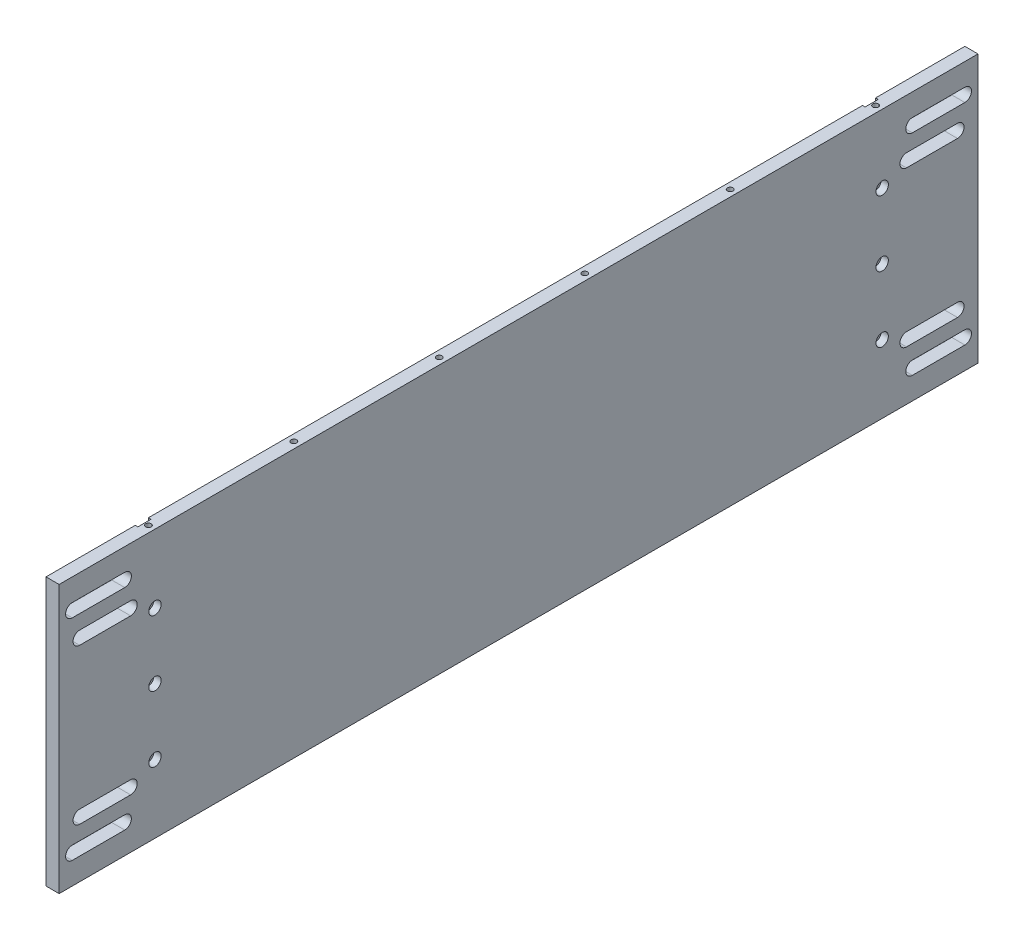
from build123d import *

# Parameters (mm, degrees)
SKETCH1_W                                      = 444.5
SKETCH1_H                                      = 129.54
BOSS_EXTRUDE1_DEPTH                            = 6.35
CBORE_FOR_6_SOCKET_HEAD_CAP_SCREW1_D           = 3.6576
CBORE_FOR_6_SOCKET_HEAD_CAP_SCREW1_CBORE_D     = 5.999999938
CBORE_FOR_6_SOCKET_HEAD_CAP_SCREW1_CBORE_DEPTH = 3.5052
CUT_EXTRUDE1_DEPTH                             = 7.35
TAP_DRILL_FOR_6_32_TAP1_D                      = 2.7051
TAP_DRILL_FOR_6_32_TAP1_DEPTH                  = 17.78
TAP_DRILL_FOR_6_32_TAP1_TIP                    = 0.81269403
TAP_DRILL_FOR_6_32_TAP2_D                      = 2.7051
TAP_DRILL_FOR_6_32_TAP2_DEPTH                  = 17.78
TAP_DRILL_FOR_6_32_TAP2_TIP                    = 0.81269403
SKETCH21_W                                     = 6.35
SKETCH21_H                                     = 129.54
CUT_EXTRUDE2_DEPTH                             = 1.27


with BuildPart() as part:
    # Sketch1 → Boss-Extrude1 (new body)
    with BuildSketch(Plane(origin=(0, 0, 0), x_dir=(0, 0, -1), z_dir=(1, 0, 0))):
        with Locations((222.25, 64.77)):
            Rectangle(SKETCH1_W, SKETCH1_H)
    extrude(amount=BOSS_EXTRUDE1_DEPTH)

    # CBORE for #6 Socket Head Cap Screw1 (through all)
    with Locations(Plane(origin=(6.35, 0, 0), x_dir=(0, 0, -1), z_dir=(1, 0, 0))):
        with Locations((46.355, 64.77), (398.145, 64.77), (46.355, 96.52), (46.355, 33.02), (398.145, 96.52), (398.145, 33.02)):
            CounterBoreHole(CBORE_FOR_6_SOCKET_HEAD_CAP_SCREW1_D / 2, CBORE_FOR_6_SOCKET_HEAD_CAP_SCREW1_CBORE_D / 2, CBORE_FOR_6_SOCKET_HEAD_CAP_SCREW1_CBORE_DEPTH)

    # Sketch16 → Cut-Extrude1 (cut, through all)
    with BuildSketch(Plane(origin=(6.35, 0, 0), x_dir=(0, 0, -1), z_dir=(1, 0, 0))):
        with BuildLine():
            Line((6.35, 118.7704), (31.75, 118.7704))
            ThreePointArc((31.75, 118.7704), (34.9504, 115.57), (31.75, 112.3696))
            Line((31.75, 112.3696), (6.35, 112.3696))
            ThreePointArc((6.35, 112.3696), (3.1496, 115.57), (6.35, 118.7704))
        make_face()
        with BuildLine():
            Line((434.5817, 24.095), (409.9183, 24.095))
            ThreePointArc((409.9183, 24.095), (406.7433, 27.27), (409.9183, 30.445))
            Line((409.9183, 30.445), (434.5817, 30.445))
            ThreePointArc((434.5817, 30.445), (437.7567, 27.27), (434.5817, 24.095))
        make_face()
        with BuildLine():
            Line((434.5817, 105.445), (409.9183, 105.445))
            ThreePointArc((409.9183, 105.445), (406.7433, 102.27), (409.9183, 99.095))
            Line((409.9183, 99.095), (434.5817, 99.095))
            ThreePointArc((434.5817, 99.095), (437.7567, 102.27), (434.5817, 105.445))
        make_face()
        with BuildLine():
            Line((6.35, 10.7696), (31.75, 10.7696))
            ThreePointArc((31.75, 10.7696), (34.9504, 13.97), (31.75, 17.1704))
            Line((31.75, 17.1704), (6.35, 17.1704))
            ThreePointArc((6.35, 17.1704), (3.1496, 13.97), (6.35, 10.7696))
        make_face()
        with BuildLine():
            Line((438.15, 118.7704), (412.75, 118.7704))
            ThreePointArc((412.75, 118.7704), (409.5496, 115.57), (412.75, 112.3696))
            Line((412.75, 112.3696), (438.15, 112.3696))
            ThreePointArc((438.15, 112.3696), (441.3504, 115.57), (438.15, 118.7704))
        make_face()
        with BuildLine():
            Line((9.9183, 105.445), (34.5817, 105.445))
            ThreePointArc((34.5817, 105.445), (37.7567, 102.27), (34.5817, 99.095))
            Line((34.5817, 99.095), (9.9183, 99.095))
            ThreePointArc((9.9183, 99.095), (6.7433, 102.27), (9.9183, 105.445))
        make_face()
        with BuildLine():
            Line((9.9183, 24.095), (34.5817, 24.095))
            ThreePointArc((34.5817, 24.095), (37.7567, 27.27), (34.5817, 30.445))
            Line((34.5817, 30.445), (9.9183, 30.445))
            ThreePointArc((9.9183, 30.445), (6.7433, 27.27), (9.9183, 24.095))
        make_face()
        with BuildLine():
            Line((438.15, 10.7696), (412.75, 10.7696))
            ThreePointArc((412.75, 10.7696), (409.5496, 13.97), (412.75, 17.1704))
            Line((412.75, 17.1704), (438.15, 17.1704))
            ThreePointArc((438.15, 17.1704), (441.3504, 13.97), (438.15, 10.7696))
        make_face()
    extrude(amount=-CUT_EXTRUDE1_DEPTH, mode=Mode.SUBTRACT)

    # Tap Drill for #6-32 Tap1
    with Locations(Plane(origin=(62.747088364, 129.54, -312.392951164), x_dir=(0, 0, 1), z_dir=(0, 1, 0))):
        with Locations((-85.752048836, -59.572088364), (-15.394048836, -59.572088364), (54.963951164, -59.572088364), (125.321951164, -59.572088364), (195.679951164, -59.572088364), (266.037951164, -59.572088364), (266.037951164, -129.930088364), (266.037951164, -200.288088364), (266.037951164, -270.646088364), (266.037951164, -341.004088364), (266.037951164, -411.362088364), (195.679951164, -411.362088364), (125.321951164, -411.362088364), (54.963951164, -411.362088364), (-15.394048836, -411.362088364), (-85.752048836, -411.362088364), (-85.752048836, -341.004088364), (-85.752048836, -270.646088364), (-85.752048836, -200.288088364), (-85.752048836, -129.930088364)):
            Hole(TAP_DRILL_FOR_6_32_TAP1_D / 2, depth=TAP_DRILL_FOR_6_32_TAP1_DEPTH)
            with Locations((0, 0, -(TAP_DRILL_FOR_6_32_TAP1_DEPTH + TAP_DRILL_FOR_6_32_TAP1_TIP / 2))):  # 118° drill point
                Cone(0, TAP_DRILL_FOR_6_32_TAP1_D / 2, TAP_DRILL_FOR_6_32_TAP1_TIP, mode=Mode.SUBTRACT)

    # Tap Drill for #6-32 Tap2
    with Locations(Plane(origin=(62.747088364, 0, -312.392951164), x_dir=(0, 0, -1), z_dir=(0, -1, 0))):
        with Locations((85.752048836, -411.362088364), (15.394048836, -411.362088364), (-54.963951164, -411.362088364), (-125.321951164, -411.362088364), (-195.679951164, -411.362088364), (-266.037951164, -411.362088364), (-266.037951164, -341.004088364), (-266.037951164, -270.646088364), (-266.037951164, -200.288088364), (-266.037951164, -129.930088364), (-266.037951164, -59.572088364), (-195.679951164, -59.572088364), (-125.321951164, -59.572088364), (-54.963951164, -59.572088364), (15.394048836, -59.572088364), (85.752048836, -59.572088364), (85.752048836, -130.006288364), (85.752048836, -200.364288364), (85.752048836, -270.722288364), (85.752048836, -341.080288364)):
            Hole(TAP_DRILL_FOR_6_32_TAP2_D / 2, depth=TAP_DRILL_FOR_6_32_TAP2_DEPTH)
            with Locations((0, 0, -(TAP_DRILL_FOR_6_32_TAP2_DEPTH + TAP_DRILL_FOR_6_32_TAP2_TIP / 2))):  # 118° drill point
                Cone(0, TAP_DRILL_FOR_6_32_TAP2_D / 2, TAP_DRILL_FOR_6_32_TAP2_TIP, mode=Mode.SUBTRACT)

    # Sketch21 → Cut-Extrude2 (cut)
    with BuildSketch(Plane.ZY):
        with Locations((-398.145, 64.77)):
            Rectangle(SKETCH21_W, SKETCH21_H)
        with Locations((-46.355, 64.77)):
            Rectangle(SKETCH21_W, SKETCH21_H)
    extrude(amount=-CUT_EXTRUDE2_DEPTH, mode=Mode.SUBTRACT)


solid = part.part
